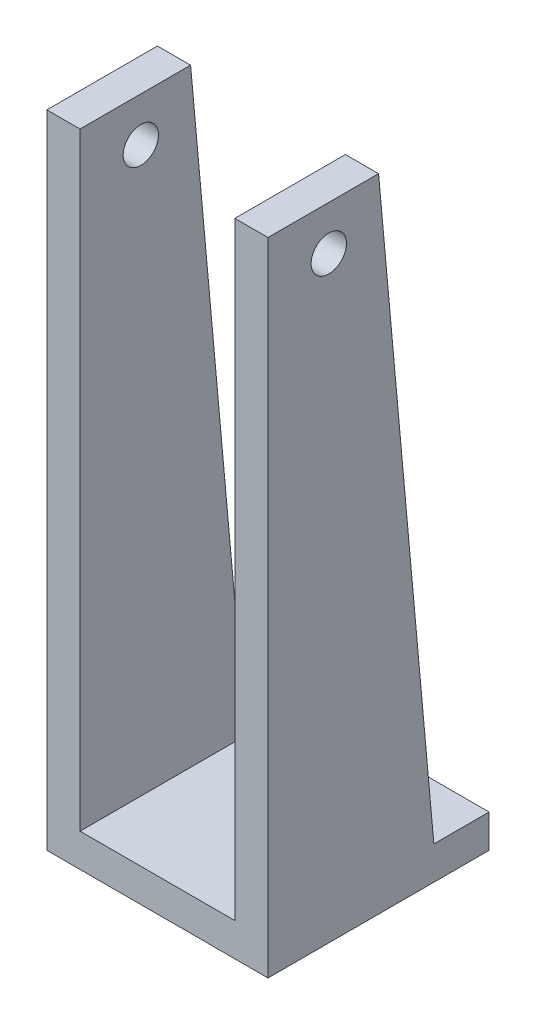
from build123d import *

# Parameters (mm, degrees)
SKETCH_1_W          = 20
SKETCH_1_H          = 20
EXTRUDE_1_DEPTH     = 3
EXTRUDE_2_DEPTH     = 3
EXTRUDE_3_DEPTH     = 3
SKETCH_6_R          = 1.6
CUT_EXTRUDE_1_DEPTH = 21
SKETCH_8_R          = 2
CUT_EXTRUDE_2_DEPTH = 4


with BuildPart() as part:
    # 草图1 → 凸台-拉伸1 (new body)
    with BuildSketch(Plane(origin=(0, 0, 0), x_dir=(1, 0, 0), z_dir=(0, 1, 0))):
        Rectangle(SKETCH_1_W, SKETCH_1_H)
    extrude(amount=EXTRUDE_1_DEPTH)

    # 草图4 → 凸台-拉伸2 (add)
    with BuildSketch(Plane.ZY.offset(10)):
        Polygon((10, 3), (10, 58), (0, 58), (-5, 3), align=None)
    extrude(amount=-EXTRUDE_2_DEPTH)

    # 草图5 → 凸台-拉伸3 (add)
    with BuildSketch(Plane(origin=(10, 0, 0), x_dir=(0, 0, -1), z_dir=(1, 0, 0))):
        Polygon((-10, 3), (5, 3), (0, 58), (-10, 58), align=None)
    extrude(amount=-EXTRUDE_3_DEPTH)

    # 草图6 → 切除-拉伸1 (cut, through all)
    with BuildSketch(Plane(origin=(10, 0, 0), x_dir=(0, 0, -1), z_dir=(1, 0, 0))):
        with Locations((-4.5, 54)):
            Circle(SKETCH_6_R)
    extrude(amount=-CUT_EXTRUDE_1_DEPTH, mode=Mode.SUBTRACT)

    # 草图8 → 切除-拉伸2 (cut, through all)
    with BuildSketch(Plane(origin=(0, 3, 0), x_dir=(1, 0, 0), z_dir=(0, 1, 0))):
        Circle(SKETCH_8_R)
    extrude(amount=-CUT_EXTRUDE_2_DEPTH, mode=Mode.SUBTRACT)


solid = part.part
